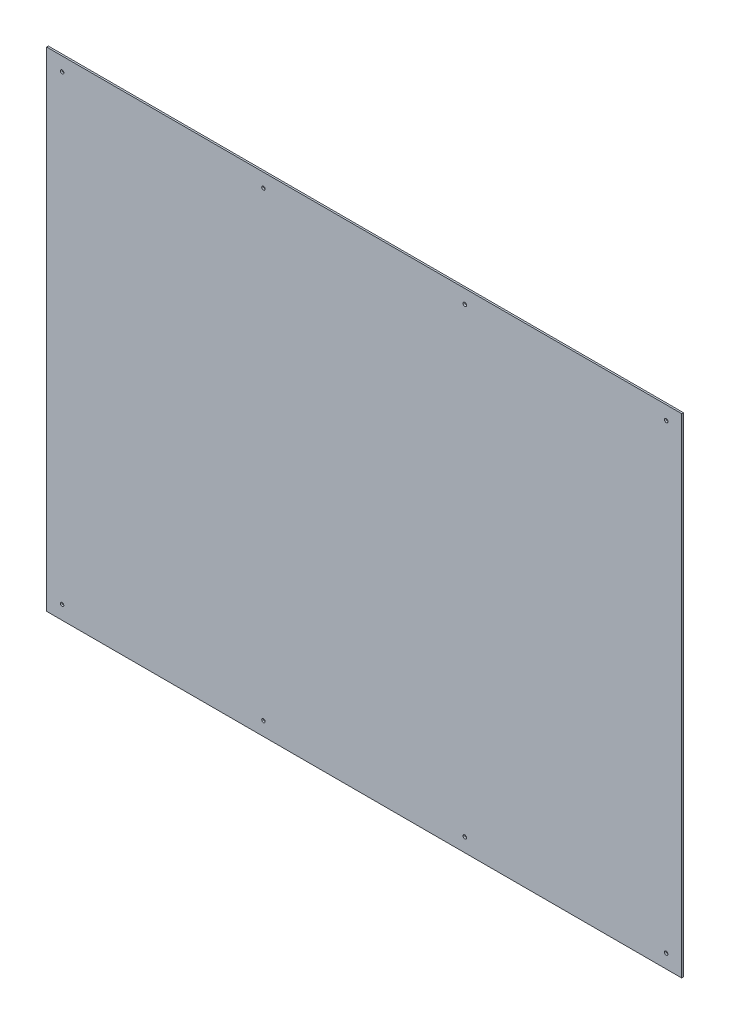
from build123d import *

# Parameters (mm, degrees)
SKETCH1_W                   = 1171.575
SKETCH1_H                   = 901.7
BOSS_EXTRUDE1_DEPTH         = 3.175
F_1_4_0_25_DIAMETER_HOLE1_D = 6.35
LPATTERN1_COUNT             = 4
LPATTERN1_PITCH             = 371.475
LPATTERN1_COUNT_DIR2        = 2
LPATTERN1_PITCH_DIR2        = 850.9


with BuildPart() as part:
    # Sketch1 → Boss-Extrude1 (new body)
    with BuildSketch(Plane.XY):
        Rectangle(SKETCH1_W, SKETCH1_H)
    extrude(amount=BOSS_EXTRUDE1_DEPTH)

    # 1/4 (0.25) Diameter Hole1 (through all)
    with Locations(Plane.XY.offset(3.175)):
        with Locations((-557.2125, 425.45)):
            f_1_4_0_25_diameter_hole1 = Hole(F_1_4_0_25_DIAMETER_HOLE1_D / 2)

    # LPattern1: 1_4 _0.25_ Diameter Hole1 4 × 2
    with Locations(*[(i * LPATTERN1_PITCH, -j * LPATTERN1_PITCH_DIR2, 0) for i in range(LPATTERN1_COUNT) for j in range(LPATTERN1_COUNT_DIR2) if (i, j) != (0, 0)]):
        add(f_1_4_0_25_diameter_hole1, mode=Mode.SUBTRACT)


solid = part.part
